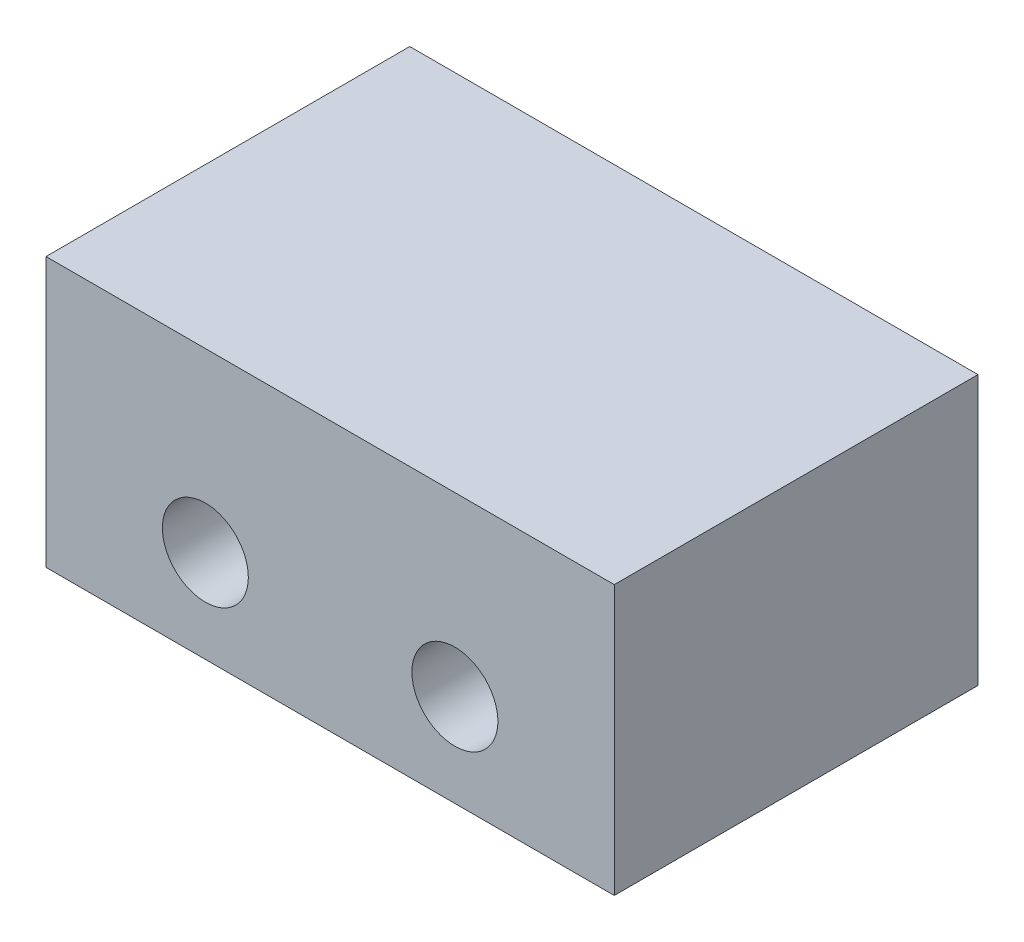
from build123d import *

# Parameters (mm, degrees)
SKETCH2_W           = 19.84
SKETCH2_H           = 9.4
SKETCH2_R           = 1.5
BOSS_EXTRUDE1_DEPTH = 12.7


with BuildPart() as part:
    # Sketch2 → Boss-Extrude1 (new body)
    with BuildSketch(Plane.XY):
        with Locations((9.92, 4.7)):
            Rectangle(SKETCH2_W, SKETCH2_H)
        with Locations((5.564, 3.23)):
            Circle(SKETCH2_R, mode=Mode.SUBTRACT)
        with Locations((14.276, 3.23)):
            Circle(SKETCH2_R, mode=Mode.SUBTRACT)
    extrude(amount=BOSS_EXTRUDE1_DEPTH)


solid = part.part
